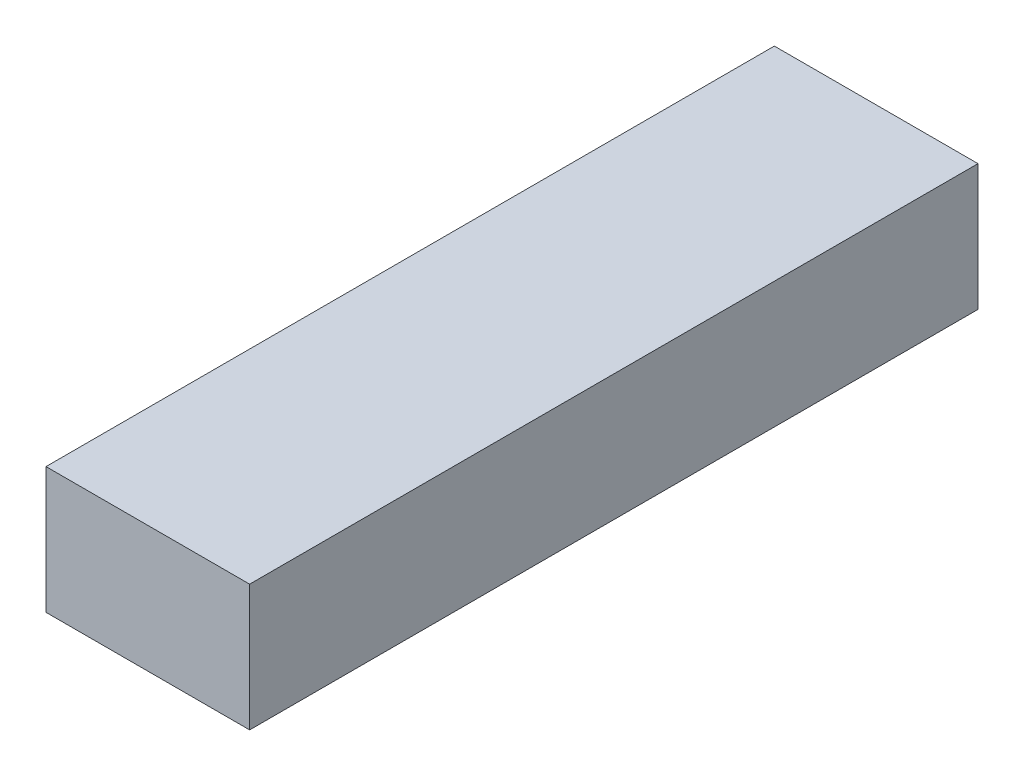
from build123d import *

# Parameters (mm, degrees)
SKETCH_2_W      = 33.55
SKETCH_2_H      = 20.8
EXTRUDE_2_DEPTH = 120


with BuildPart() as part:
    # 스케치2 → 보스-돌출2 (new body)
    with BuildSketch(Plane(origin=(0, 0, 44.199975), x_dir=(-1, 0, 0), z_dir=(0, 0, -1))):
        with Locations((88.339215729, 44.248001191)):
            Rectangle(SKETCH_2_W, SKETCH_2_H)
    extrude(amount=EXTRUDE_2_DEPTH)


solid = part.part
